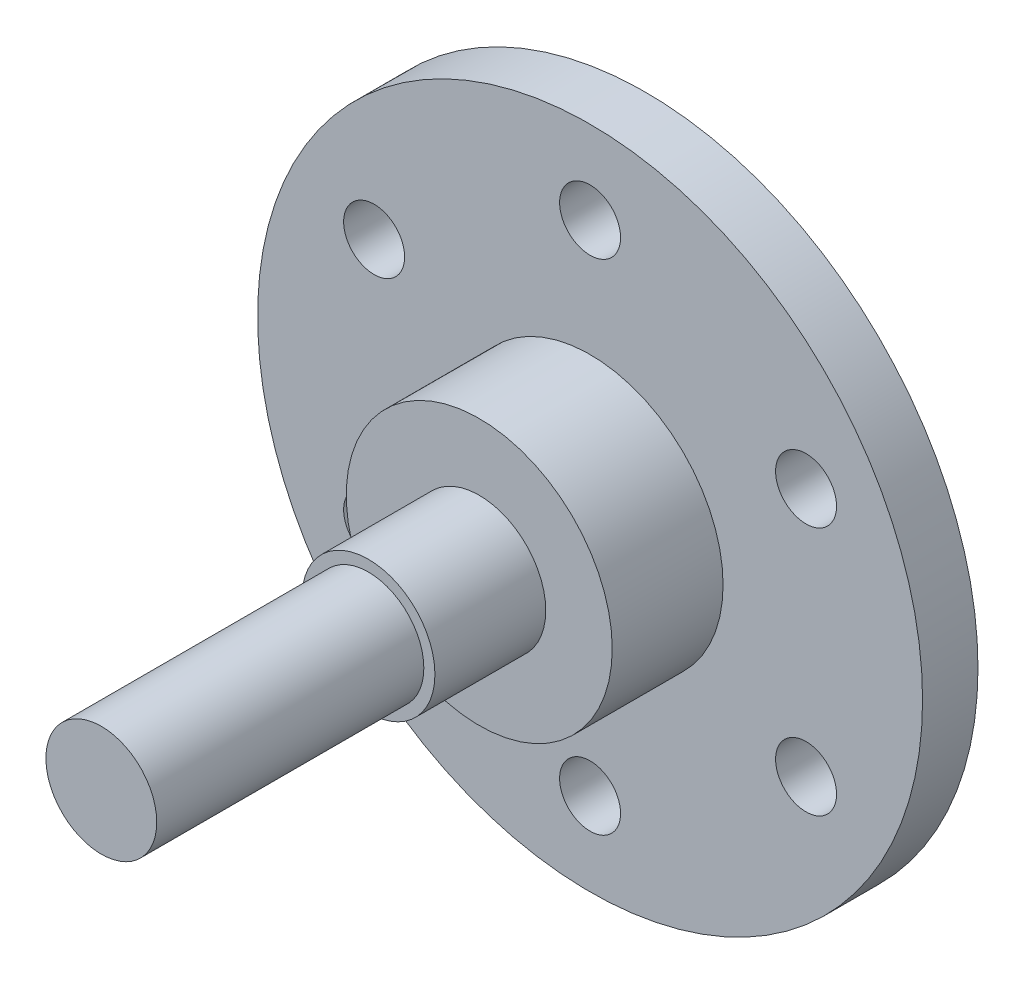
from build123d import *

# Parameters (mm, degrees)
SKETCH_1_R      = 30
SKETCH_1_R_2    = 2.75
EXTRUDE_1_DEPTH = 5
SKETCH_2_R      = 12
EXTRUDE_2_DEPTH = 10
SKETCH_3_R      = 6
EXTRUDE_3_DEPTH = 10
SKETCH_5_R      = 5
EXTRUDE_4_DEPTH = 24.1


with BuildPart() as part:
    # 草图1 → 凸台-拉伸1 (new body)
    with BuildSketch(Plane.XY):
        Circle(SKETCH_1_R)
        with Locations((0, 22.5)):
            Circle(SKETCH_1_R_2, mode=Mode.SUBTRACT)
        with Locations((19.485571585, 11.25)):
            Circle(SKETCH_1_R_2, mode=Mode.SUBTRACT)
        with Locations((19.485571585, -11.25)):
            Circle(SKETCH_1_R_2, mode=Mode.SUBTRACT)
        with Locations((0, -22.5)):
            Circle(SKETCH_1_R_2, mode=Mode.SUBTRACT)
        with Locations((-19.485571585, -11.25)):
            Circle(SKETCH_1_R_2, mode=Mode.SUBTRACT)
        with Locations((-19.485571585, 11.25)):
            Circle(SKETCH_1_R_2, mode=Mode.SUBTRACT)
    extrude(amount=EXTRUDE_1_DEPTH)

    # 草图2 → 凸台-拉伸2 (add)
    with BuildSketch(Plane.XY.offset(5)):
        Circle(SKETCH_2_R)
    extrude(amount=EXTRUDE_2_DEPTH)

    # 草图3 → 凸台-拉伸3 (add)
    with BuildSketch(Plane.XY.offset(15)):
        Circle(SKETCH_3_R)
    extrude(amount=EXTRUDE_3_DEPTH)

    # 草图5 → 凸台-拉伸4 (add)
    with BuildSketch(Plane.XY.offset(25)):
        Circle(SKETCH_5_R)
    extrude(amount=EXTRUDE_4_DEPTH)


solid = part.part
